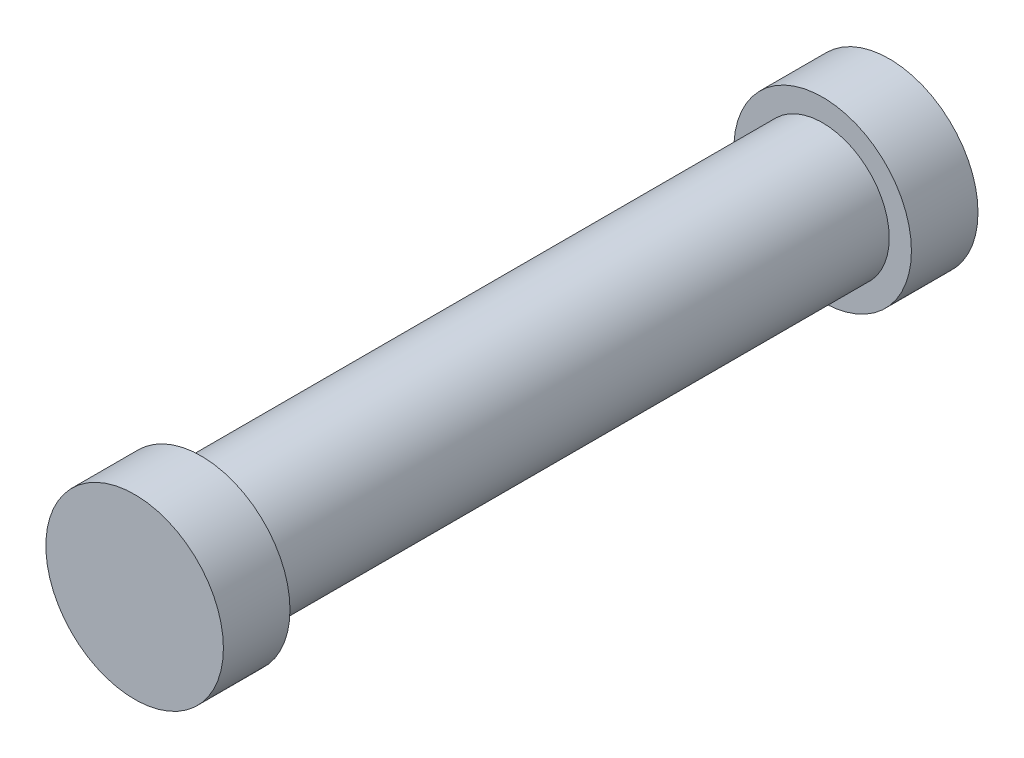
from build123d import *

# Parameters (mm, degrees)
SKETCH1_R           = 25.4
BOSS_EXTRUDE1_DEPTH = 19.05
SKETCH2_R           = 19.05
BOSS_EXTRUDE3_DEPTH = 177.8
SKETCH4_R           = 25.4
BOSS_EXTRUDE4_DEPTH = 19.05


with BuildPart() as part:
    # Sketch1 → Boss-Extrude1 (new body)
    with BuildSketch(Plane.XY):
        Circle(SKETCH1_R)
    extrude(amount=BOSS_EXTRUDE1_DEPTH)

    # Sketch2 → Boss-Extrude3 (add)
    with BuildSketch(Plane.XY.offset(19.05)):
        Circle(SKETCH2_R)
    extrude(amount=BOSS_EXTRUDE3_DEPTH)

    # Sketch4 → Boss-Extrude4 (add)
    with BuildSketch(Plane.XY.offset(196.85)):
        Circle(SKETCH4_R)
    extrude(amount=BOSS_EXTRUDE4_DEPTH)


solid = part.part
